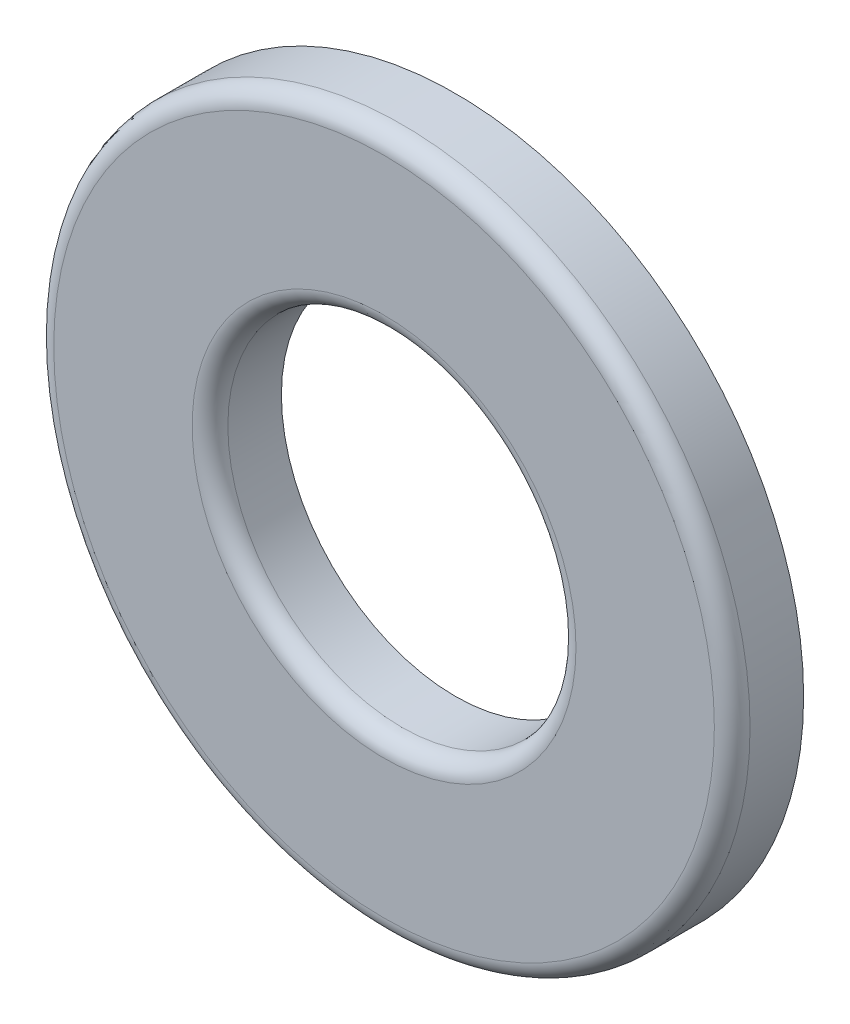
from build123d import *

# Parameters (mm, degrees)
SKETCH3_R                = 3.9624
SKETCH3_R_2              = 1.9812
BOSS_EXTRUDE1_DEPTH      = 0.4064
BOSS_EXTRUDE1_DEPTH_BACK = 0.4064
FILLET1_R                = 0.2032


with BuildPart() as part:
    # Sketch3 → Boss-Extrude1 (new body, two sides)
    with BuildSketch(Plane.XY) as boss_extrude1_sk:
        Circle(SKETCH3_R)
        Circle(SKETCH3_R_2, mode=Mode.SUBTRACT)
    extrude(amount=BOSS_EXTRUDE1_DEPTH)
    extrude(boss_extrude1_sk.sketch, amount=-BOSS_EXTRUDE1_DEPTH_BACK)

    # Fillet1
    fillet1_edges = [part.edges().sort_by_distance(p)[0] for p in [
        (-3.9624, 0, 0.4064),
        (-1.9812, 0, 0.4064),
    ]]
    fillet(fillet1_edges, radius=FILLET1_R)


solid = part.part
